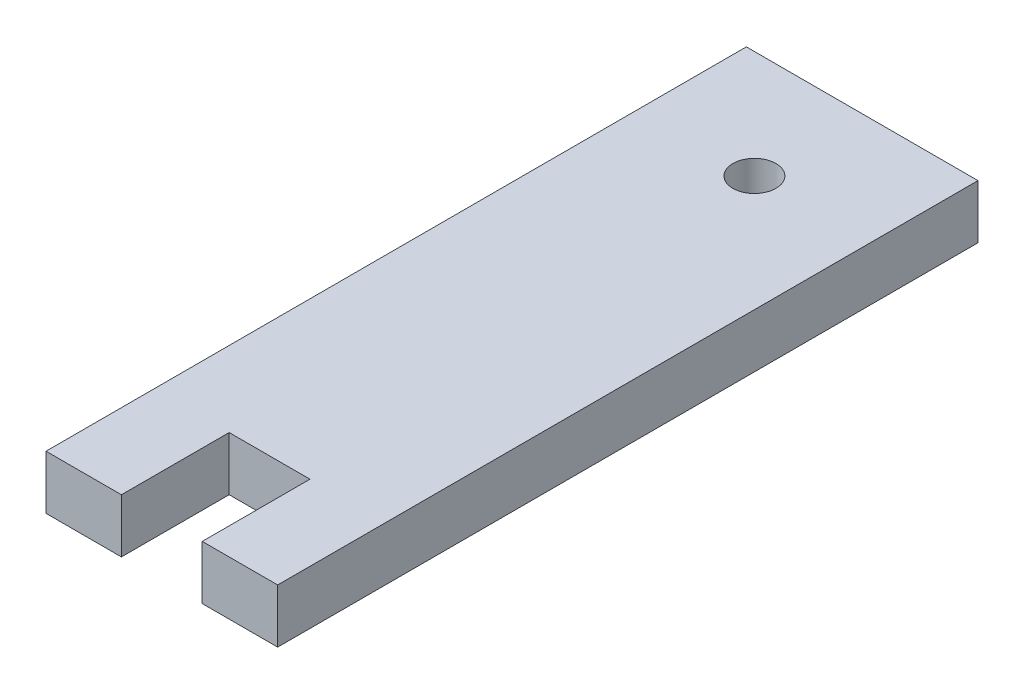
from build123d import *

# Parameters (mm, degrees)
SKETCH1_R           = 2
BOSS_EXTRUDE1_DEPTH = 5


with BuildPart() as part:
    # Sketch1 → Boss-Extrude1 (new body)
    with BuildSketch(Plane(origin=(0, 0, 0), x_dir=(1, 0, 0), z_dir=(0, 1, 0))):
        Polygon((-10.75, 32.5), (10.75, 32.5), (10.75, -32.5), (3.75, -32.5), (3.75, -22.5), (-3.75, -22.5), (-3.75, -32.5), (-10.75, -32.5), align=None)
        with Locations((0, 22.5)):
            Circle(SKETCH1_R, mode=Mode.SUBTRACT)
    extrude(amount=BOSS_EXTRUDE1_DEPTH)


solid = part.part
